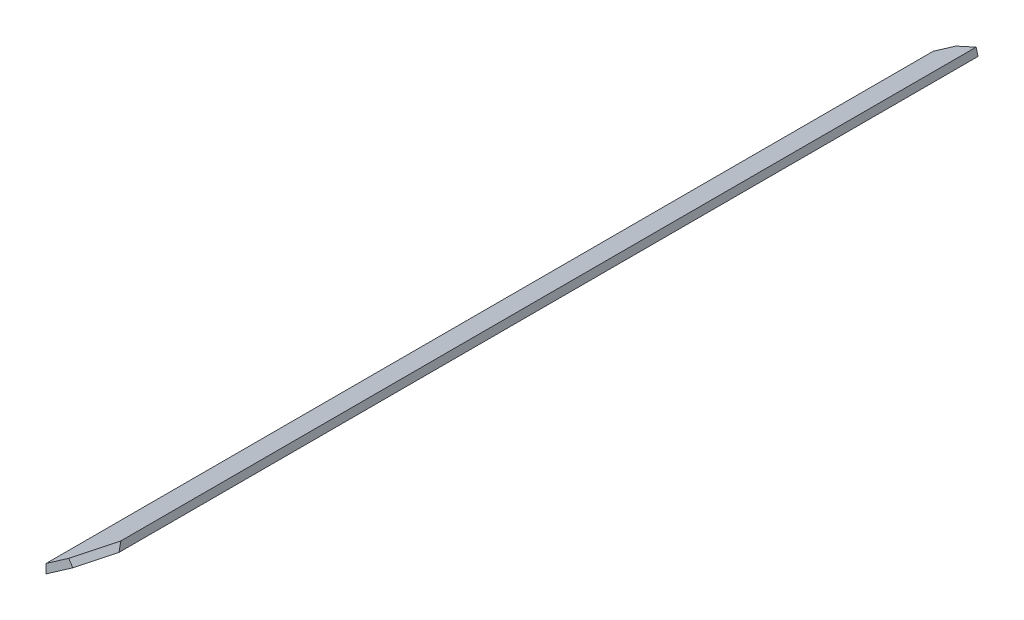
from build123d import *

# Parameters (mm, degrees)
SALIENTE_EXTRUIR2_DEPTH      = 21
SALIENTE_EXTRUIR2_DEPTH_BACK = 77
CORTAR_EXTRUIR2_DEPTH        = 5.534624471


with BuildPart() as part:
    # Croquis1 → Saliente-Extruir2 (new body, two sides)
    with BuildSketch(Plane.XY) as saliente_extruir2_sk:
        Polygon((4, -95.47461527), (-2.5, -100), (-2.5, -99), (4, -94.47461527), align=None)
    extrude(amount=SALIENTE_EXTRUIR2_DEPTH)
    extrude(saliente_extruir2_sk.sketch, amount=-SALIENTE_EXTRUIR2_DEPTH_BACK)

    # Croquis3 → Cortar-Extruir2 (cut, through all)
    with BuildSketch(Plane(origin=(45.607014753, -65.507269237, 0), x_dir=(0.820689363, 0.571374632, 0), z_dir=(-0.571374632, 0.820689363, 0))):
        Polygon((-50.697641098, 77), (-50.697641098, 75.231357415), (-55.571592416, 77), align=None)
        Polygon((-50.697641098, -21), (-50.697641098, -19.231357415), (-55.571592416, -21), align=None)
    extrude(amount=-CORTAR_EXTRUIR2_DEPTH, mode=Mode.SUBTRACT)


solid = part.part
